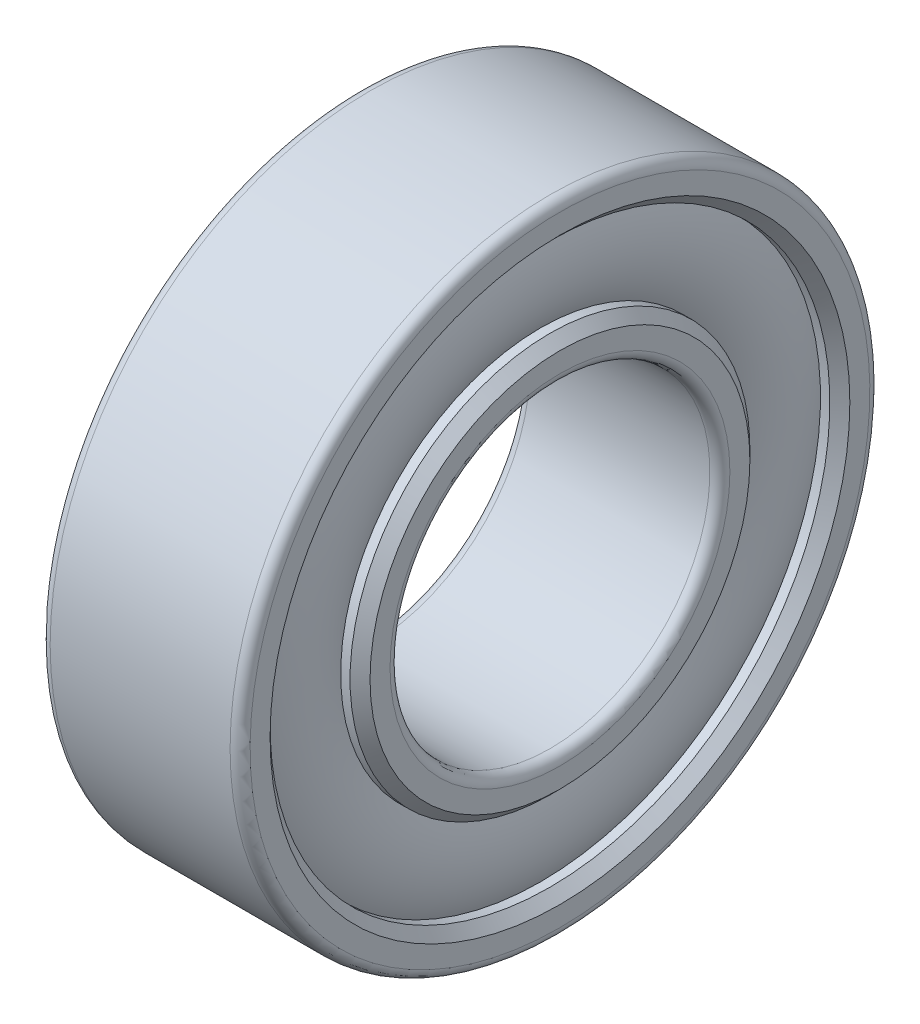
from build123d import *


with BuildPart() as part:
    # Sketch1 → Revolve1 (revolve)
    with BuildSketch(Plane.XY):
        with BuildLine():
            Line((0, -4.25), (0, -4.75))
            Line((0, -4.75), (0.25, -5))
            Line((0.25, -5), (0.484435563, -5))
            ThreePointArc((0.484435563, -5), (0.25, -6), (0.484435563, -7))
            Line((0.484435563, -7), (0.25, -7))
            Line((0.25, -7), (0, -7.25))
            Line((0, -7.25), (0, -7.75))
            ThreePointArc((0, -7.75), (0.073223305, -7.926776695), (0.25, -8))
            Line((0.25, -8), (4.75, -8))
            ThreePointArc((4.75, -8), (4.926776695, -7.926776695), (5, -7.75))
            Line((5, -7.75), (5, -7.25))
            Line((5, -7.25), (4.75, -7))
            Line((4.75, -7), (4.515564437, -7))
            ThreePointArc((4.515564437, -7), (4.75, -6), (4.515564437, -5))
            Line((4.515564437, -5), (4.75, -5))
            Line((4.75, -5), (5, -4.75))
            Line((5, -4.75), (5, -4.25))
            ThreePointArc((5, -4.25), (4.926776695, -4.073223305), (4.75, -4))
            Line((4.75, -4), (0.25, -4))
            ThreePointArc((0.25, -4), (0.073223305, -4.073223305), (0, -4.25))
        make_face()
    revolve(axis=Axis((0, 0, 0), (1, 0, 0)))


solid = part.part
